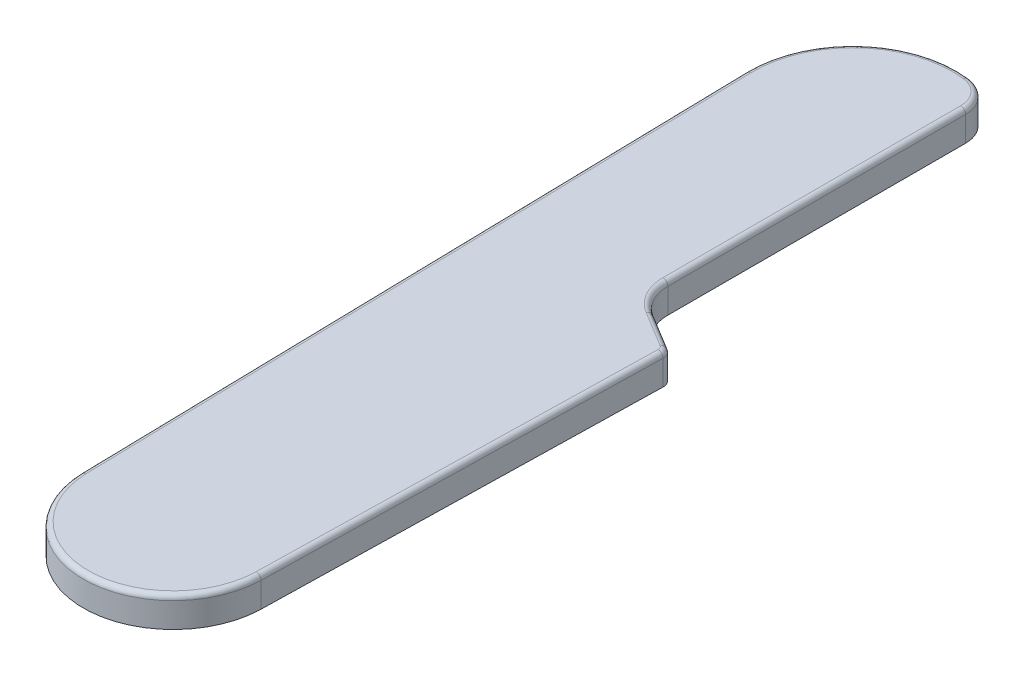
from build123d import *

# Parameters (mm, degrees)
BOSS_EXTRUDE1_DEPTH = 3
FILLET1_R           = 4
FILLET2_R           = 3
FILLET3_R           = 1
FILLET5_R           = 0.5
SKETCH1_R           = 1
CUT_EXTRUDE1_DEPTH  = 2


with BuildPart() as part:
    # cover_itself → Boss-Extrude1 (new body)
    with BuildSketch(Plane(origin=(0, 0, 0), x_dir=(1, 0, 0), z_dir=(0, 1, 0))):
        with BuildLine():
            Line((-8.997858244, -0.196333965), (-10.480917414, 67.771305568))
            ThreePointArc((-10.480917414, 67.771305568), (-5.982302771, 76.608947935), (3.869342172, 77.743209027))
            Line((3.869342172, 77.743209027), (3.869342172, 43.384098405))
            Line((3.869342172, 43.384098405), (9.869342172, 39.743209027))
            Line((9.869342172, 39.743209027), (8.997858244, -0.196333965))
            ThreePointArc((8.997858244, -0.196333965), (0, -9), (-8.997858244, -0.196333965))
        make_face()
    extrude(amount=BOSS_EXTRUDE1_DEPTH)

    # Fillet1
    fillet1_edges = [part.edges().sort_by_distance(p)[0] for p in [
        (3.869342172, 1.5, -43.384098405),
    ]]
    fillet(fillet1_edges, radius=FILLET1_R)

    # Fillet2
    fillet2_edges = [part.edges().sort_by_distance(p)[0] for p in [
        (3.869342172, 1.5, -77.743209027),
    ]]
    fillet(fillet2_edges, radius=FILLET2_R)

    # Fillet3
    fillet3_edges = [part.edges().sort_by_distance(p)[0] for p in [
        (9.869342172, 1.5, -39.743209027),
    ]]
    fillet(fillet3_edges, radius=FILLET3_R)

    # Fillet5
    fillet5_edges = [part.edges().sort_by_distance(p)[0] for p in [
        (-9.739387829, 3, -33.787485802),
        (3.869342172, 3, -60.534214462),
        (4.383630471, 3, -43.673589393),
        (-7.054041855, 3, -75.755154705),
        (3.110493996, 3, -77.427046765),
        (7.585003856, 3, -41.129379545),
        (9.733712071, 3, -39.668799805),
        (0, 3, 9),
        (9.427302793, 3, -19.484831093),
    ]]
    fillet(fillet5_edges, radius=FILLET5_R)

    # Sketch1 → Cut-Extrude1 (cut)
    with BuildSketch(Plane.XZ):
        with Locations((-2.705062156, -1.67)):
            Circle(SKETCH1_R)
        with Locations((6.76984482, -35.216036183)):
            Circle(SKETCH1_R)
        with Locations((-5.399070001, -69.616613762)):
            Circle(SKETCH1_R)
    extrude(amount=-CUT_EXTRUDE1_DEPTH, mode=Mode.SUBTRACT)


solid = part.part
